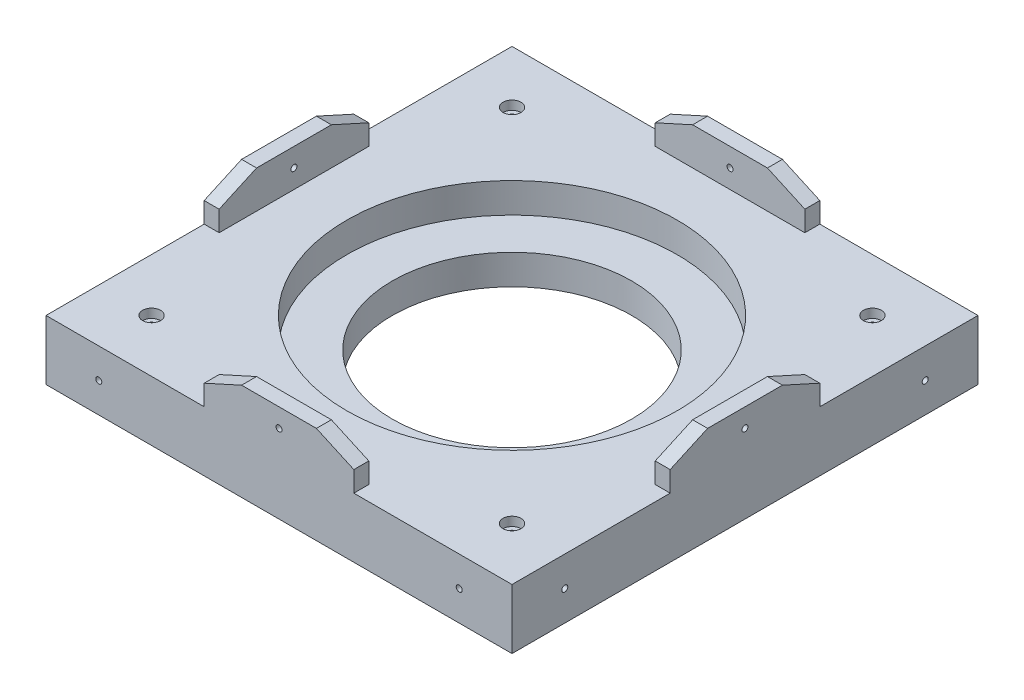
from build123d import *

# Parameters (mm, degrees)
SKETCH1_R            = 1.5
SKETCH1_R_2          = 73
BOSS_EXTRUDE1_DEPTH  = 20
SKETCH7_R            = 73
SKETCH7_R_2          = 52.25
BOSS_EXTRUDE2_DEPTH  = 10
SKETCH8_R            = 73
BOSS_EXTRUDE3_DEPTH  = 10
BOSS_EXTRUDE4_DEPTH  = 20
SKETCH10_R           = 55.2
SKETCH10_R_2         = 52.25
CUT_EXTRUDE1_DEPTH   = 10
SKETCH11_R           = 40
CUT_EXTRUDE2_DEPTH   = 50
SKETCH12_R           = 3
SKETCH12_R_2         = 1.5
CUT_EXTRUDE3_DEPTH   = 3
SKETCH13_W           = 50
SKETCH13_H           = 6.823606938
BOSS_EXTRUDE5_DEPTH  = 5
BOSS_EXTRUDE6_DEPTH  = 5
BOSS_EXTRUDE7_DEPTH  = 5
BOSS_EXTRUDE8_DEPTH  = 5
SKETCH19_R           = 1.5
CUT_EXTRUDE4_DEPTH   = 5
SKETCH20_R           = 1.5
CUT_EXTRUDE5_DEPTH   = 5
SKETCH21_R           = 1.5
CUT_EXTRUDE6_DEPTH   = 5
SKETCH22_R           = 1.5
CUT_EXTRUDE7_DEPTH   = 5
SKETCH23_R           = 1.5
SKETCH23_R_2         = 1
BOSS_EXTRUDE9_DEPTH  = 5
SKETCH24_R           = 1.5
SKETCH24_R_2         = 1
BOSS_EXTRUDE10_DEPTH = 5
SKETCH25_R           = 1.5
SKETCH25_R_2         = 1
BOSS_EXTRUDE11_DEPTH = 5
SKETCH26_R           = 1.5
SKETCH26_R_2         = 1
BOSS_EXTRUDE12_DEPTH = 5


with BuildPart() as part:
    # Sketch1 → Boss-Extrude1 (new body)
    with BuildSketch(Plane(origin=(0, 0, 0), x_dir=(1, 0, 0), z_dir=(0, 1, 0))):
        with BuildLine():
            Line((77.460838348, -75.098177713), (77.460838348, 74.577424045))
            ThreePointArc((77.460838348, 74.577424045), (76.578174547, 76.708362964), (74.447235628, 77.591026765))
            Line((74.447235628, 77.591026765), (-75.22836613, 77.591026765))
            ThreePointArc((-75.22836613, 77.591026765), (-77.359305049, 76.708362964), (-78.24196885, 74.577424045))
            Line((-78.24196885, 74.577424045), (-78.24196885, -75.098177713))
            ThreePointArc((-78.24196885, -75.098177713), (-77.359305049, -77.229116632), (-75.22836613, -78.111780433))
            Line((-75.22836613, -78.111780433), (74.447235628, -78.111780433))
            ThreePointArc((74.447235628, -78.111780433), (76.578174547, -77.229116632), (77.460838348, -75.098177713))
        make_face()
        with Locations((-60.604326536, -60.47413812)):
            Circle(SKETCH1_R, mode=Mode.SUBTRACT)
        with Locations((-60.604326536, 59.953384452)):
            Circle(SKETCH1_R, mode=Mode.SUBTRACT)
        with Locations((59.823196035, 59.953384452)):
            Circle(SKETCH1_R, mode=Mode.SUBTRACT)
        with Locations((59.823196035, -60.47413812)):
            Circle(SKETCH1_R, mode=Mode.SUBTRACT)
        with Locations((-0.390565251, -0.260376834)):
            Circle(SKETCH1_R_2, mode=Mode.SUBTRACT)
    extrude(amount=BOSS_EXTRUDE1_DEPTH)

    # Sketch7 → Boss-Extrude2 (add)
    with BuildSketch(Plane(origin=(0, 20, 0), x_dir=(1, 0, 0), z_dir=(0, 1, 0))):
        with Locations((-0.390565251, -0.260376834)):
            Circle(SKETCH7_R)
        with Locations((-0.390565251, -0.260376834)):
            Circle(SKETCH7_R_2, mode=Mode.SUBTRACT)
    extrude(amount=-BOSS_EXTRUDE2_DEPTH)

    # Sketch8 → Boss-Extrude3 (add)
    with BuildSketch(Plane.XZ.offset(-10)):
        with Locations((-0.390565251, 0.260376834)):
            Circle(SKETCH8_R)
    extrude(amount=BOSS_EXTRUDE3_DEPTH)

    # Sketch9 → Boss-Extrude4 (add)
    with BuildSketch(Plane(origin=(0, 20, 0), x_dir=(1, 0, 0), z_dir=(0, 1, 0))):
        with BuildLine():
            ThreePointArc((-75.22836613, -78.111780433), (-77.359305049, -77.229116632), (-78.24196885, -75.098177713))
            Line((-78.24196885, -75.098177713), (-78.24196885, -78.111780433))
            Line((-78.24196885, -78.111780433), (-75.22836613, -78.111780433))
        make_face()
        with BuildLine():
            Line((77.460838348, -78.111780433), (77.460838348, -75.098177713))
            ThreePointArc((77.460838348, -75.098177713), (76.578174547, -77.229116632), (74.447235628, -78.111780433))
            Line((74.447235628, -78.111780433), (77.460838348, -78.111780433))
        make_face()
        with BuildLine():
            Line((77.460838348, 77.591026765), (74.447235628, 77.591026765))
            ThreePointArc((74.447235628, 77.591026765), (76.578174547, 76.708362964), (77.460838348, 74.577424045))
            Line((77.460838348, 74.577424045), (77.460838348, 77.591026765))
        make_face()
        with BuildLine():
            Line((-75.22836613, 77.591026765), (-78.24196885, 77.591026765))
            Line((-78.24196885, 77.591026765), (-78.24196885, 74.577424045))
            ThreePointArc((-78.24196885, 74.577424045), (-77.359305049, 76.708362964), (-75.22836613, 77.591026765))
        make_face()
    extrude(amount=-BOSS_EXTRUDE4_DEPTH)

    # Sketch10 → Cut-Extrude1 (cut)
    with BuildSketch(Plane(origin=(0, 20, 0), x_dir=(1, 0, 0), z_dir=(0, 1, 0))):
        with Locations((-0.390565251, -0.260376834)):
            Circle(SKETCH10_R)
        with Locations((-0.390565251, -0.260376834)):
            Circle(SKETCH10_R_2, mode=Mode.SUBTRACT)
    extrude(amount=-CUT_EXTRUDE1_DEPTH, mode=Mode.SUBTRACT)

    # Sketch11 → Cut-Extrude2 (cut)
    with BuildSketch(Plane(origin=(0, 20, 0), x_dir=(1, 0, 0), z_dir=(0, 1, 0))):
        with Locations((-0.390565251, -0.260376834)):
            Circle(SKETCH11_R)
    extrude(amount=-CUT_EXTRUDE2_DEPTH, mode=Mode.SUBTRACT)

    # Sketch12 → Cut-Extrude3 (cut)
    with BuildSketch(Plane(origin=(0, 20, 0), x_dir=(1, 0, 0), z_dir=(0, 1, 0))):
        with Locations((59.823196035, 59.953384452)):
            Circle(SKETCH12_R)
        with Locations((59.823196035, 59.953384452)):
            Circle(SKETCH12_R_2, mode=Mode.SUBTRACT)
        with Locations((-60.604326536, 59.953384452)):
            Circle(SKETCH12_R)
        with Locations((-60.604326536, 59.953384452)):
            Circle(SKETCH12_R_2, mode=Mode.SUBTRACT)
        with Locations((-60.604326536, -60.47413812)):
            Circle(SKETCH12_R)
        with Locations((-60.604326536, -60.47413812)):
            Circle(SKETCH12_R_2, mode=Mode.SUBTRACT)
        with Locations((59.823196035, -60.47413812)):
            Circle(SKETCH12_R)
        with Locations((59.823196035, -60.47413812)):
            Circle(SKETCH12_R_2, mode=Mode.SUBTRACT)
    extrude(amount=-CUT_EXTRUDE3_DEPTH, mode=Mode.SUBTRACT)

    # Sketch13 → Boss-Extrude5 (add)
    with BuildSketch(Plane.ZY.offset(78.24196885)):
        with Locations((0.260376834, 23.411803469)):
            Rectangle(SKETCH13_W, SKETCH13_H)
        Polygon((12.760376834, 32.49492606), (25.260376834, 26.823606938), (-24.739623166, 26.823606938), (-12.239623166, 32.49492606), align=None)
    extrude(amount=-BOSS_EXTRUDE5_DEPTH)

    # Sketch14 → Boss-Extrude6 (add)
    with BuildSketch(Plane(origin=(77.460838348, 0, 0), x_dir=(0, 0, -1), z_dir=(1, 0, 0))):
        Polygon((-25.260376834, 26.823606938), (-25.260376834, 20), (24.739623166, 20), (24.739623166, 26.823606938), (12.239623166, 32.49492606), (-12.760376834, 32.49492606), align=None)
    extrude(amount=-BOSS_EXTRUDE6_DEPTH)

    # Sketch17 → Boss-Extrude7 (add)
    with BuildSketch(Plane(origin=(0, 0, -77.591026765), x_dir=(-1, 0, 0), z_dir=(0, 0, -1))):
        Polygon((-77.460838348, 0), (78.24196885, 0), (78.24196885, 20), (25.390565251, 20), (25.390565251, 26.823606938), (12.890565251, 32.49492606), (-12.109434749, 32.49492606), (-24.609434749, 26.823606938), (-24.609434749, 20), (-77.460838348, 20), align=None)
    extrude(amount=-BOSS_EXTRUDE7_DEPTH)

    # Sketch18 → Boss-Extrude8 (add)
    with BuildSketch(Plane.XY.offset(78.111780433)):
        Polygon((-25.390565251, 20), (24.609434749, 20), (24.609434749, 26.823606938), (12.109434749, 32.49492606), (-12.890565251, 32.49492606), (-25.390565251, 26.823606938), align=None)
    extrude(amount=-BOSS_EXTRUDE8_DEPTH)

    # Sketch19 → Cut-Extrude4 (cut)
    with BuildSketch(Plane.ZY.offset(78.24196885)):
        with Locations((0.260376834, 26.24746303)):
            Circle(SKETCH19_R)
        with Locations((60.47413812, 10)):
            Circle(SKETCH19_R)
        with Locations((-59.953384452, 10)):
            Circle(SKETCH19_R)
    extrude(amount=-CUT_EXTRUDE4_DEPTH, mode=Mode.SUBTRACT)

    # Sketch20 → Cut-Extrude5 (cut)
    with BuildSketch(Plane(origin=(77.460838348, 0, 0), x_dir=(0, 0, -1), z_dir=(1, 0, 0))):
        with Locations((-60.47413812, 10)):
            Circle(SKETCH20_R)
        with Locations((59.953384452, 10)):
            Circle(SKETCH20_R)
        with Locations((-0.260376834, 26.24746303)):
            Circle(SKETCH20_R)
    extrude(amount=-CUT_EXTRUDE5_DEPTH, mode=Mode.SUBTRACT)

    # Sketch21 → Cut-Extrude6 (cut)
    with BuildSketch(Plane(origin=(0, 0, -77.591026765), x_dir=(-1, 0, 0), z_dir=(0, 0, -1))):
        with Locations((-59.823196035, 10)):
            Circle(SKETCH21_R)
        with Locations((0.390565251, 26.24746303)):
            Circle(SKETCH21_R)
        with Locations((60.604326536, 10)):
            Circle(SKETCH21_R)
    extrude(amount=-CUT_EXTRUDE6_DEPTH, mode=Mode.SUBTRACT)

    # Sketch22 → Cut-Extrude7 (cut)
    with BuildSketch(Plane.XY.offset(78.111780433)):
        with Locations((59.823196035, 10)):
            Circle(SKETCH22_R)
        with Locations((-0.390565251, 26.24746303)):
            Circle(SKETCH22_R)
        with Locations((-60.604326536, 10)):
            Circle(SKETCH22_R)
    extrude(amount=-CUT_EXTRUDE7_DEPTH, mode=Mode.SUBTRACT)

    # Sketch23 → Boss-Extrude9 (add)
    with BuildSketch(Plane.ZY.offset(78.24196885)):
        with Locations((60.47413812, 10)):
            Circle(SKETCH23_R)
        with Locations((60.47413812, 10)):
            Circle(SKETCH23_R_2, mode=Mode.SUBTRACT)
        with Locations((-59.953384452, 10)):
            Circle(SKETCH23_R)
        with Locations((-59.953384452, 10)):
            Circle(SKETCH23_R_2, mode=Mode.SUBTRACT)
        with Locations((0.260376834, 26.24746303)):
            Circle(SKETCH23_R)
        with Locations((0.260376834, 26.24746303)):
            Circle(SKETCH23_R_2, mode=Mode.SUBTRACT)
    extrude(amount=-BOSS_EXTRUDE9_DEPTH)

    # Sketch24 → Boss-Extrude10 (add)
    with BuildSketch(Plane.XY.offset(78.111780433)):
        with Locations((-60.604326536, 10)):
            Circle(SKETCH24_R)
        with Locations((-60.604326536, 10)):
            Circle(SKETCH24_R_2, mode=Mode.SUBTRACT)
        with Locations((-0.390565251, 26.24746303)):
            Circle(SKETCH24_R)
        with Locations((-0.390565251, 26.24746303)):
            Circle(SKETCH24_R_2, mode=Mode.SUBTRACT)
        with Locations((59.823196035, 10)):
            Circle(SKETCH24_R)
        with Locations((59.823196035, 10)):
            Circle(SKETCH24_R_2, mode=Mode.SUBTRACT)
    extrude(amount=-BOSS_EXTRUDE10_DEPTH)

    # Sketch25 → Boss-Extrude11 (add)
    with BuildSketch(Plane(origin=(77.460838348, 0, 0), x_dir=(0, 0, -1), z_dir=(1, 0, 0))):
        with Locations((-60.47413812, 10)):
            Circle(SKETCH25_R)
        with Locations((-60.47413812, 10)):
            Circle(SKETCH25_R_2, mode=Mode.SUBTRACT)
        with Locations((59.953384452, 10)):
            Circle(SKETCH25_R)
        with Locations((59.953384452, 10)):
            Circle(SKETCH25_R_2, mode=Mode.SUBTRACT)
        with Locations((-0.260376834, 26.24746303)):
            Circle(SKETCH25_R)
        with Locations((-0.260376834, 26.24746303)):
            Circle(SKETCH25_R_2, mode=Mode.SUBTRACT)
    extrude(amount=-BOSS_EXTRUDE11_DEPTH)

    # Sketch26 → Boss-Extrude12 (add)
    with BuildSketch(Plane(origin=(0, 0, -77.591026765), x_dir=(-1, 0, 0), z_dir=(0, 0, -1))):
        with Locations((-59.823196035, 10)):
            Circle(SKETCH26_R)
        with Locations((-59.823196035, 10)):
            Circle(SKETCH26_R_2, mode=Mode.SUBTRACT)
        with Locations((60.604326536, 10)):
            Circle(SKETCH26_R)
        with Locations((60.604326536, 10)):
            Circle(SKETCH26_R_2, mode=Mode.SUBTRACT)
        with Locations((0.390565251, 26.24746303)):
            Circle(SKETCH26_R)
        with Locations((0.390565251, 26.24746303)):
            Circle(SKETCH26_R_2, mode=Mode.SUBTRACT)
    extrude(amount=-BOSS_EXTRUDE12_DEPTH)


solid = part.part
